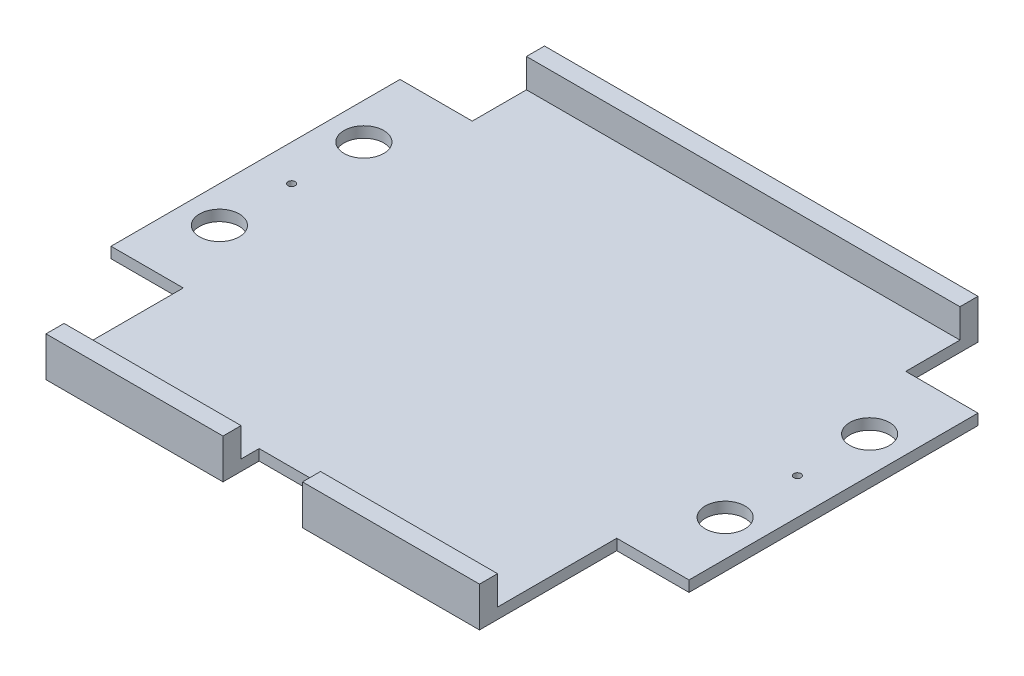
from build123d import *

# Parameters (mm, degrees)
SKETCH1_W               = 120
SKETCH1_H               = 133
BOSS_EXTRUDE1_DEPTH     = 3
SKETCH2_W               = 120
SKETCH2_H               = 5
BOSS_EXTRUDE2_DEPTH     = 8
SKETCH3_W               = 22
SKETCH3_H               = 10
CUT_EXTRUDE1_DEPTH      = 1
CUT_EXTRUDE1_DEPTH_BACK = 12
SKETCH4_W               = 120
SKETCH4_H               = 5
BOSS_EXTRUDE3_DEPTH     = 11
SKETCH5_W               = 80
SKETCH5_H               = 3
BOSS_EXTRUDE4_DEPTH     = 80
SKETCH6_R               = 1
SKETCH6_R_2             = 5.5
CUT_EXTRUDE2_DEPTH      = 80


with BuildPart() as part:
    # Sketch1 → Boss-Extrude1 (new body)
    with BuildSketch(Plane(origin=(0, 0, 0), x_dir=(1, 0, 0), z_dir=(0, 1, 0))):
        Rectangle(SKETCH1_W, SKETCH1_H)
    extrude(amount=BOSS_EXTRUDE1_DEPTH)

    # Sketch2 → Boss-Extrude2 (add)
    with BuildSketch(Plane(origin=(0, 3, 0), x_dir=(1, 0, 0), z_dir=(0, 1, 0))):
        with Locations((0, -64)):
            Rectangle(SKETCH2_W, SKETCH2_H)
    extrude(amount=BOSS_EXTRUDE2_DEPTH)

    # Sketch3 → Cut-Extrude1 (cut, two sides)
    with BuildSketch(Plane(origin=(0, 11, 0), x_dir=(1, 0, 0), z_dir=(0, 1, 0))) as cut_extrude1_sk:
        with Locations((0, -61.5)):
            Rectangle(SKETCH3_W, SKETCH3_H)
    extrude(amount=CUT_EXTRUDE1_DEPTH, mode=Mode.SUBTRACT)
    extrude(cut_extrude1_sk.sketch, amount=-CUT_EXTRUDE1_DEPTH_BACK, mode=Mode.SUBTRACT)

    # Sketch4 → Boss-Extrude3 (add)
    with BuildSketch(Plane(origin=(0, 0, 0), x_dir=(1, 0, 0), z_dir=(0, 1, 0))):
        with Locations((0, 69)):
            Rectangle(SKETCH4_W, SKETCH4_H)
    extrude(amount=BOSS_EXTRUDE3_DEPTH)

    # Sketch5 → Boss-Extrude4 (add)
    with BuildSketch(Plane(origin=(0, 0, 0), x_dir=(0, 0, -1), z_dir=(1, 0, 0))):
        with Locations((11.5, 1.5)):
            Rectangle(SKETCH5_W, SKETCH5_H)
    boss_extrude4 = extrude(amount=BOSS_EXTRUDE4_DEPTH)

    # Sketch6 → Cut-Extrude2 (cut)
    with BuildSketch(Plane(origin=(0, 3, 0), x_dir=(1, 0, 0), z_dir=(0, 1, 0))):
        with Locations((70, 11.5)):
            Circle(SKETCH6_R)
        with Locations((70, 31.5)):
            Circle(SKETCH6_R_2)
        with Locations((70, -8.5)):
            Circle(SKETCH6_R_2)
    cut_extrude2 = extrude(amount=-CUT_EXTRUDE2_DEPTH, mode=Mode.SUBTRACT)

    # Mirror1: Boss-Extrude4, Cut-Extrude2 across plane
    add(boss_extrude4.mirror(Plane(origin=(0, 0, 0), x_dir=(0, 0, 1), z_dir=(1, 0, 0))))
    add(cut_extrude2.mirror(Plane(origin=(0, 0, 0), x_dir=(0, 0, 1), z_dir=(1, 0, 0))), mode=Mode.SUBTRACT)


solid = part.part
